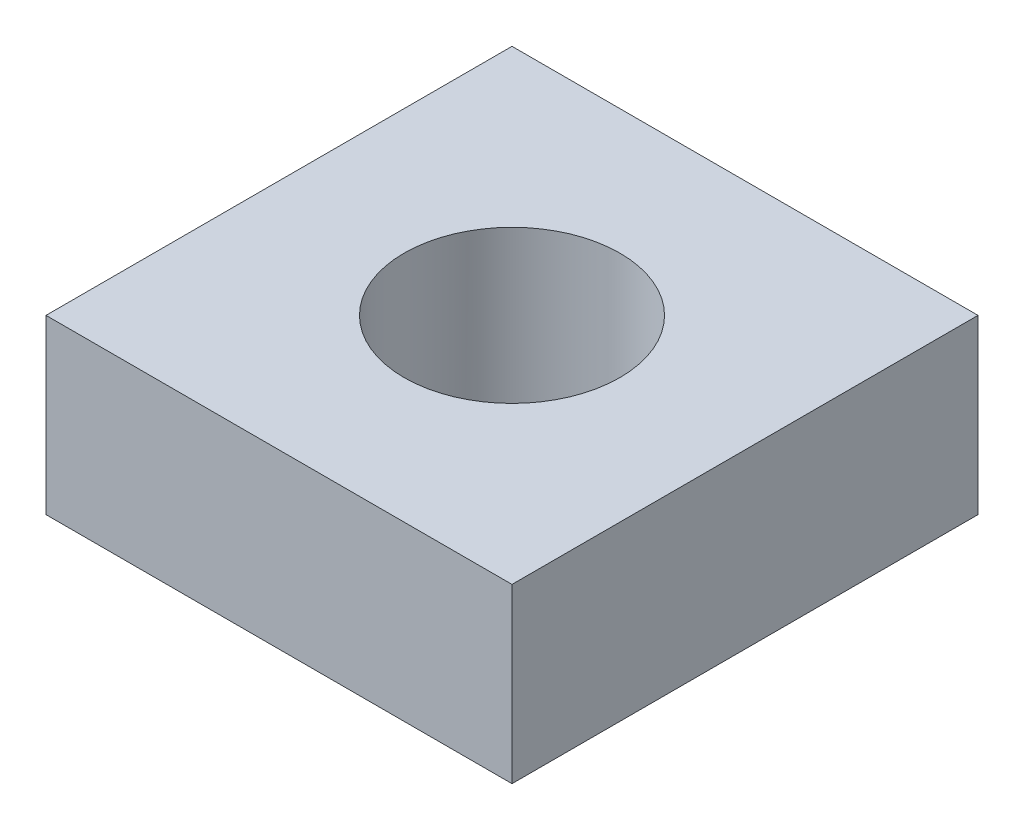
from build123d import *

# Parameters (mm, degrees)
SKETCH_1_W             = 5.4
SKETCH_1_H             = 5.4
EXTRUDE_1_DEPTH        = 2
HOLE_WIZARD_M3_1_D     = 2.5
HOLE_WIZARD_M3_1_DEPTH = 6.5
HOLE_WIZARD_M3_1_TIP   = 0.751075774


with BuildPart() as part:
    # 草图1 → 凸台-拉伸1 (new body)
    with BuildSketch(Plane(origin=(0, 0, 0), x_dir=(1, 0, 0), z_dir=(0, 1, 0))):
        Rectangle(SKETCH_1_W, SKETCH_1_H)
    extrude(amount=EXTRUDE_1_DEPTH)

    # M3 螺纹孔1
    with Locations(Plane(origin=(0, 0, 0), x_dir=(-1, 0, 0), z_dir=(0, -1, 0))):
        with Locations((0, 0)):
            Hole(HOLE_WIZARD_M3_1_D / 2, depth=HOLE_WIZARD_M3_1_DEPTH)
            with Locations((0, 0, -(HOLE_WIZARD_M3_1_DEPTH + HOLE_WIZARD_M3_1_TIP / 2))):  # 118° drill point
                Cone(0, HOLE_WIZARD_M3_1_D / 2, HOLE_WIZARD_M3_1_TIP, mode=Mode.SUBTRACT)


solid = part.part
